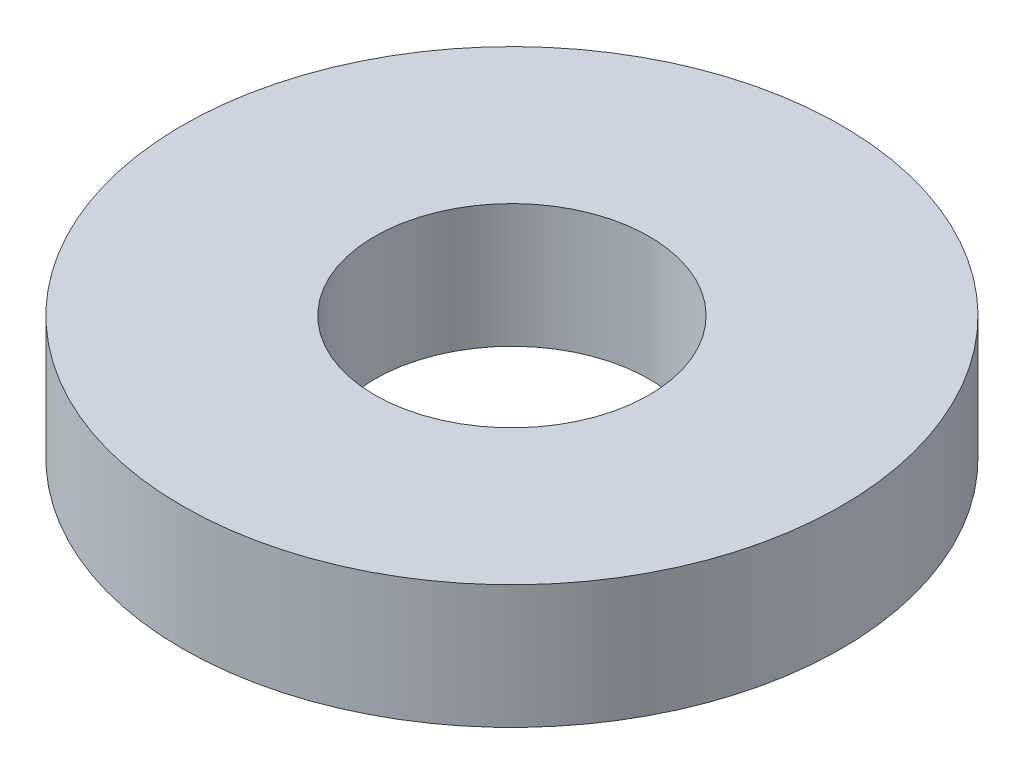
from build123d import *

# Parameters (mm, degrees)
SKETCH1_R      = 9.525
SKETCH1_R_2    = 3.96875
EXTRUDE1_DEPTH = 3.571875


with BuildPart() as part:
    # Sketch1 → Extrude1 (new body)
    with BuildSketch(Plane(origin=(0, 0, 0), x_dir=(1, 0, 0), z_dir=(0, 1, 0))):
        Circle(SKETCH1_R)
        Circle(SKETCH1_R_2, mode=Mode.SUBTRACT)
    extrude(amount=EXTRUDE1_DEPTH)


solid = part.part
